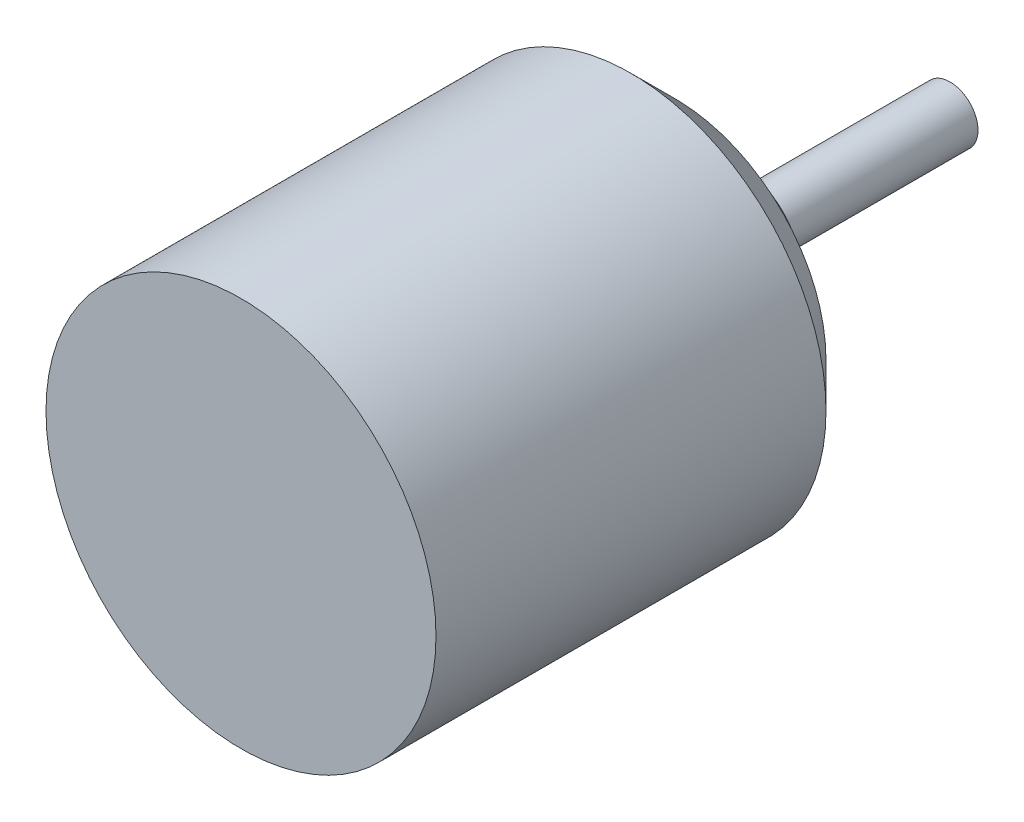
from build123d import *


with BuildPart() as part:
    # Sketch1 → Revolve1 (revolve)
    with BuildSketch(Plane(origin=(0, 0, 0), x_dir=(0, 0, -1), z_dir=(1, 0, 0))):
        Polygon((0, 0), (0, 13.97), (27.94, 13.97), (31.115, 10.795), (31.115, 4.572), (35.56, 4.572), (35.56, 2), (50.8, 2), (50.8, 0), align=None)
    revolve(axis=Axis((0, 0, 48.732583704), (0, 0, -1)))


solid = part.part
